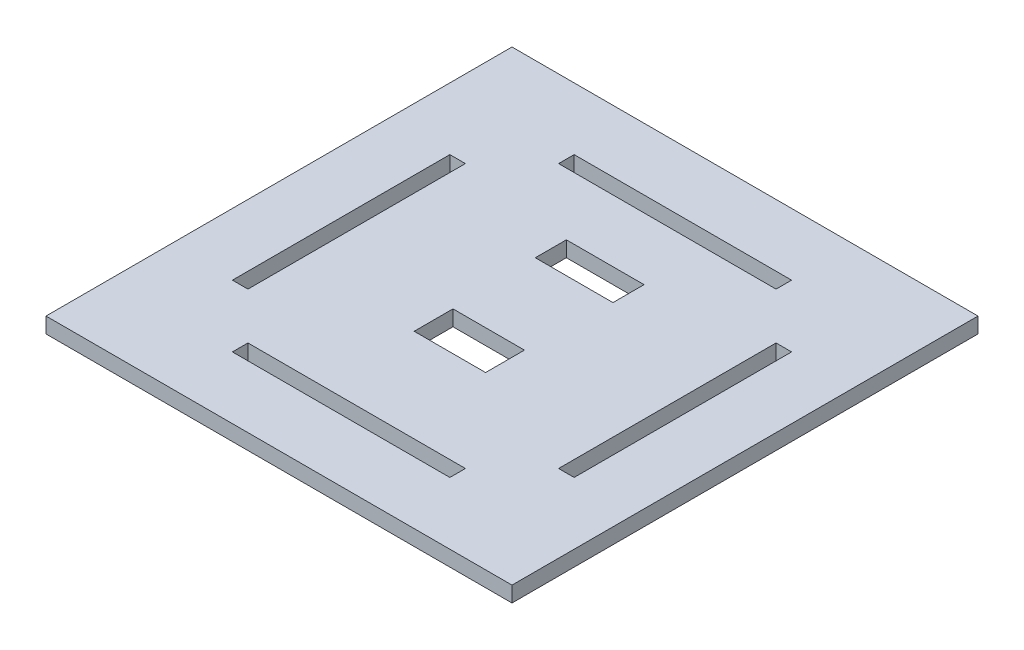
from build123d import *

# Parameters (mm, degrees)
SKETCH1_W           = 150
SKETCH1_H           = 150
SKETCH1_W_2         = 70
SKETCH1_H_2         = 5
SKETCH1_W_3         = 5
SKETCH1_H_3         = 70
SKETCH1_W_4         = 23
SKETCH1_H_4         = 12.5
SKETCH1_W_5         = 25
SKETCH1_H_5         = 10
BOSS_EXTRUDE1_DEPTH = 5


with BuildPart() as part:
    # Sketch1 → Boss-Extrude1 (new body)
    with BuildSketch(Plane(origin=(0, 0, 0), x_dir=(1, 0, 0), z_dir=(0, 1, 0))):
        with Locations((-75, 75)):
            Rectangle(SKETCH1_W, SKETCH1_H)
        with Locations((-75, 127.5)):
            Rectangle(SKETCH1_W_2, SKETCH1_H_2, mode=Mode.SUBTRACT)
        with Locations((-22.5, 75)):
            Rectangle(SKETCH1_W_3, SKETCH1_H_3, mode=Mode.SUBTRACT)
        with Locations((-127.5, 75)):
            Rectangle(SKETCH1_W_3, SKETCH1_H_3, mode=Mode.SUBTRACT)
        with Locations((-75, 22.5)):
            Rectangle(SKETCH1_W_2, SKETCH1_H_2, mode=Mode.SUBTRACT)
        with Locations((-75, 61.25)):
            Rectangle(SKETCH1_W_4, SKETCH1_H_4, mode=Mode.SUBTRACT)
        with Locations((-75, 100)):
            Rectangle(SKETCH1_W_5, SKETCH1_H_5, mode=Mode.SUBTRACT)
    extrude(amount=BOSS_EXTRUDE1_DEPTH)


solid = part.part
